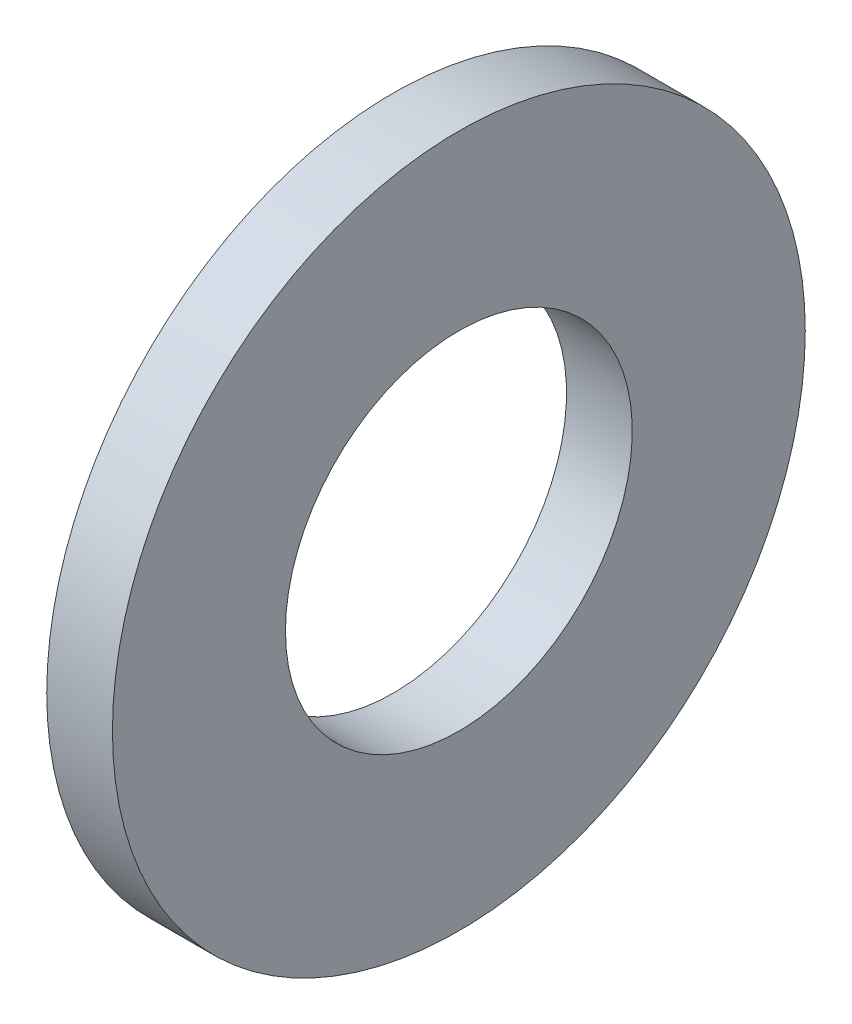
from build123d import *

# Parameters (mm, degrees)
SKETCH1_W = 2.1082
SKETCH1_H = 5.5499


with BuildPart() as part:
    # Sketch1 → Base-Revolve (revolve)
    with BuildSketch(Plane.XY):
        with Locations((-1.0541, 8.33755)):
            Rectangle(SKETCH1_W, SKETCH1_H)
    revolve(axis=Axis((-34.925, 0, 0), (1, 0, 0)))


solid = part.part
